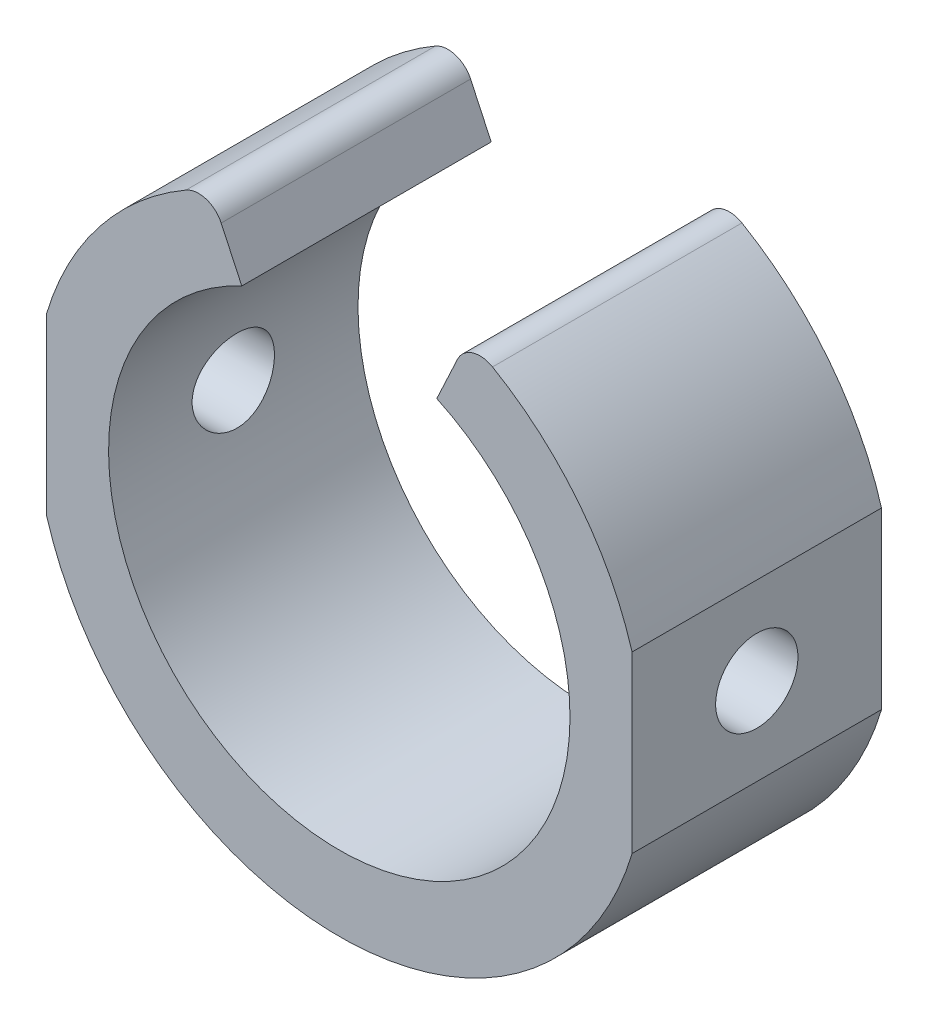
from build123d import *

# Parameters (mm, degrees)
SKETCH_1_R               = 12.25
SKETCH_1_R_2             = 9.25
EXTRUDE_1_DEPTH          = 10
CUT_EXTRUDE_1_DEPTH      = 1
CUT_EXTRUDE_1_DEPTH_BACK = 11
SKETCH_3_W               = 9.638758803
SKETCH_3_H               = 7
CUT_EXTRUDE_2_DEPTH      = 11
SKETCH_4_R               = 1.65
CUT_EXTRUDE_3_DEPTH      = 24.478713764
FILLET_1_R               = 1


with BuildPart() as part:
    # ｽｹｯﾁ1 → ﾎﾞｽ - 押し出し1 (new body)
    with BuildSketch(Plane.XY):
        Circle(SKETCH_1_R)
        Circle(SKETCH_1_R_2, mode=Mode.SUBTRACT)
    extrude(amount=EXTRUDE_1_DEPTH)

    # ｽｹｯﾁ2 → ｶｯﾄ - 押し出し1 (cut, two sides)
    with BuildSketch(Plane.XY.offset(10)) as cut_extrude_1_sk:
        with BuildLine():
            Line((-5.177073706, 11.102270391), (-3.909218921, 8.38334703))
            ThreePointArc((-3.909218921, 8.38334703), (0, 9.25), (3.909218921, 8.38334703))
            Line((3.909218921, 8.38334703), (5.177073706, 11.102270391))
            ThreePointArc((5.177073706, 11.102270391), (0, 12.25), (-5.177073706, 11.102270391))
        make_face()
    extrude(amount=CUT_EXTRUDE_1_DEPTH, mode=Mode.SUBTRACT)
    extrude(cut_extrude_1_sk.sketch, amount=-CUT_EXTRUDE_1_DEPTH_BACK, mode=Mode.SUBTRACT)

    # ｽｹｯﾁ3 → ｶｯﾄ - 押し出し2 (cut, through all)
    with BuildSketch(Plane.XY.offset(10)):
        with Locations((-16.558736284, 0)):
            Rectangle(SKETCH_3_W, SKETCH_3_H)
        with Locations((16.558736284, 0)):
            Rectangle(SKETCH_3_W, SKETCH_3_H)
    extrude(amount=-CUT_EXTRUDE_2_DEPTH, mode=Mode.SUBTRACT)

    # ｽｹｯﾁ4 → ｶｯﾄ - 押し出し3 (cut, through all)
    with BuildSketch(Plane(origin=(11.739356882, 0, 0), x_dir=(0, 0, -1), z_dir=(1, 0, 0))):
        with Locations((-5, 0)):
            Circle(SKETCH_4_R)
    extrude(amount=-CUT_EXTRUDE_3_DEPTH, mode=Mode.SUBTRACT)

    # ﾌｨﾚｯﾄ1
    fillet_1_edges = [part.edges().sort_by_distance(p)[0] for p in [
        (-5.177073706, 11.102270391, 5),
        (5.177073706, 11.102270391, 5),
    ]]
    fillet(fillet_1_edges, radius=FILLET_1_R)


solid = part.part
